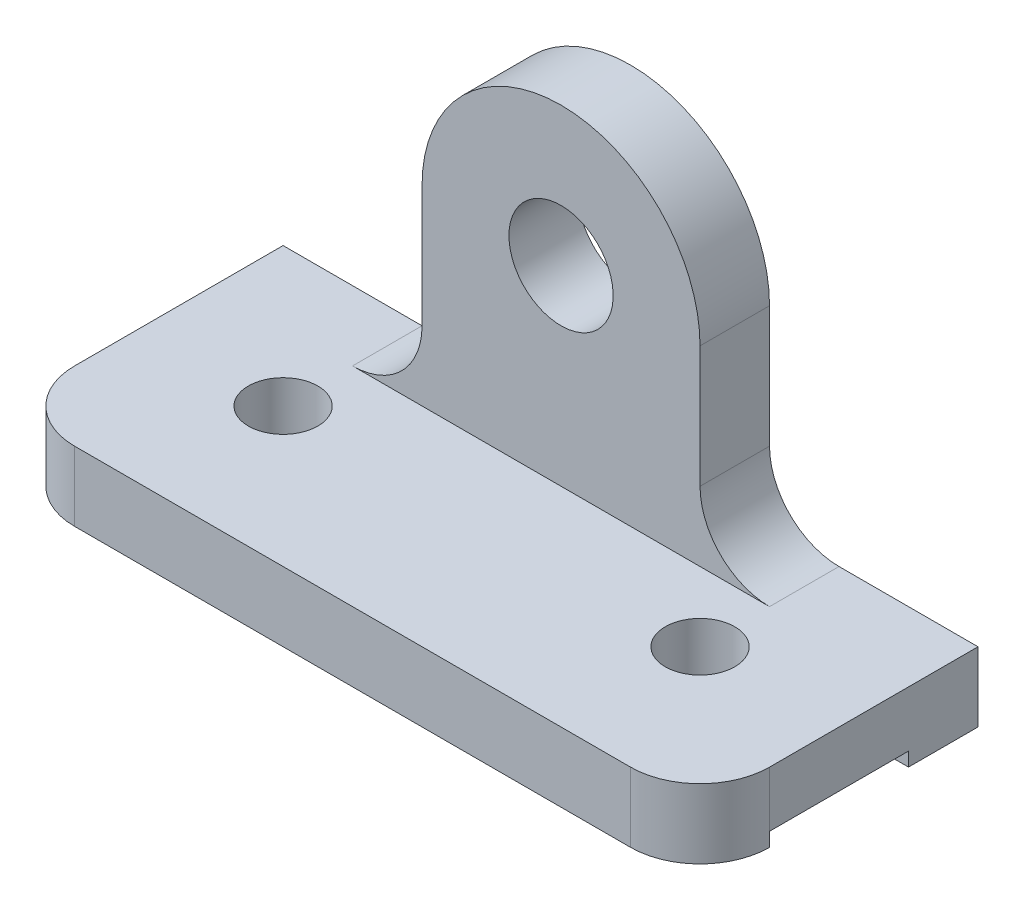
from build123d import *

# Parameters (mm, degrees)
CROQUIS1_W              = 40
CROQUIS1_H              = 10
SALIENTE_EXTRUIR1_DEPTH = 100
REDONDEO2_R             = 10
CROQUIS2_W              = 20
CROQUIS2_H              = 2
CORTAR_EXTRUIR1_DEPTH   = 100
CROQUIS3_R              = 5
CORTAR_EXTRUIR2_DEPTH   = 10
CROQUIS5_R              = 7.5
SALIENTE_EXTRUIR3_DEPTH = 10


with BuildPart() as part:
    # Croquis1 → Saliente-Extruir1 (new body)
    with BuildSketch(Plane(origin=(0, 0, 0), x_dir=(0, 0, -1), z_dir=(1, 0, 0))):
        Rectangle(CROQUIS1_W, CROQUIS1_H)
    extrude(amount=SALIENTE_EXTRUIR1_DEPTH)

    # Redondeo2
    redondeo2_edges = [part.edges().sort_by_distance(p)[0] for p in [
        (100, 0, 20),
        (0, 0, 20),
    ]]
    fillet(redondeo2_edges, radius=REDONDEO2_R)

    # Croquis2 → Cortar-Extruir1 (cut)
    with BuildSketch(Plane(origin=(100, 0, 0), x_dir=(0, 0, -1), z_dir=(1, 0, 0))):
        with Locations((0, -4)):
            Rectangle(CROQUIS2_W, CROQUIS2_H)
    extrude(amount=-CORTAR_EXTRUIR1_DEPTH, mode=Mode.SUBTRACT)

    # Croquis3 → Cortar-Extruir2 (cut)
    with BuildSketch(Plane(origin=(0, 5, 0), x_dir=(1, 0, 0), z_dir=(0, 1, 0))):
        with Locations((20, 0)):
            Circle(CROQUIS3_R)
        with Locations((80, 0)):
            Circle(CROQUIS3_R)
    extrude(amount=-CORTAR_EXTRUIR2_DEPTH, mode=Mode.SUBTRACT)

    # Croquis5 → Saliente-Extruir3 (add)
    with BuildSketch(Plane(origin=(0, 0, -20), x_dir=(-1, 0, 0), z_dir=(0, 0, -1))):
        with BuildLine():
            Line((-70, 32.5), (-70, 15))
            ThreePointArc((-70, 15), (-72.928932188, 7.928932188), (-80, 5))
            Line((-80, 5), (-20, 5))
            ThreePointArc((-20, 5), (-27.071067812, 7.928932188), (-30, 15))
            Line((-30, 15), (-30, 32.5))
            ThreePointArc((-30, 32.5), (-50, 52.5), (-70, 32.5))
        make_face()
        with Locations((-50, 32.5)):
            Circle(CROQUIS5_R, mode=Mode.SUBTRACT)
    extrude(amount=-SALIENTE_EXTRUIR3_DEPTH)


solid = part.part
